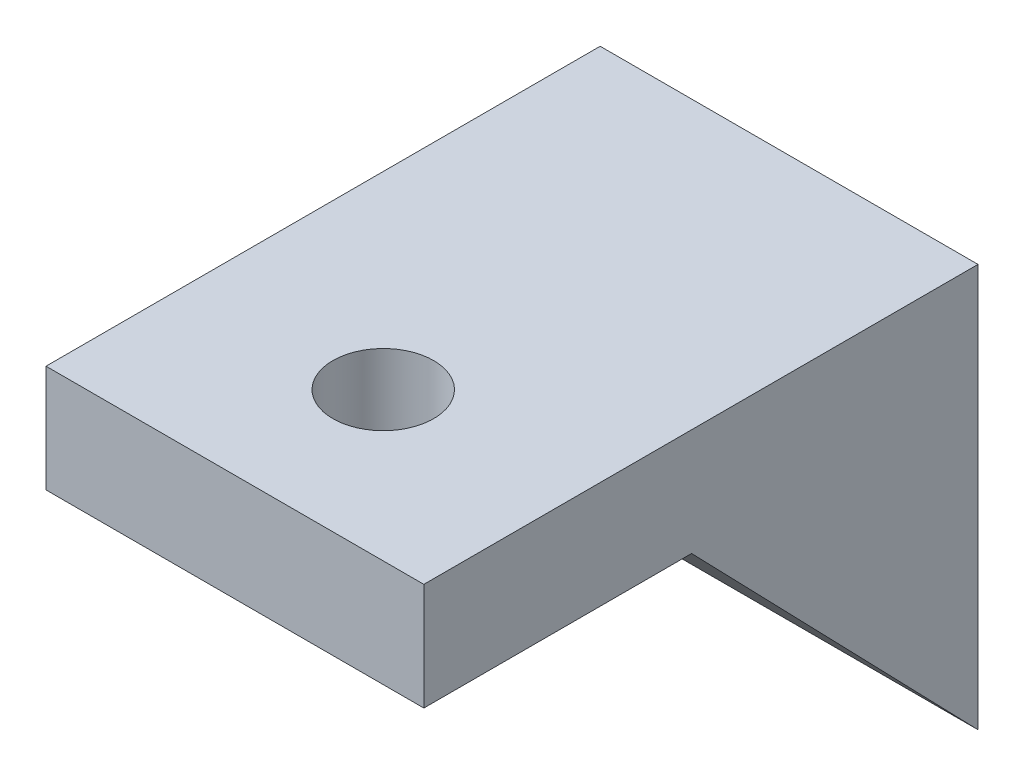
from build123d import *

# Parameters (mm, degrees)
SKETCH1_W               = 15
SKETCH1_H               = 16
BOSS_EXTRUDE1_DEPTH     = 22
CUT_EXTRUDE1_DEPTH      = 22
CUT_EXTRUDE1_DEPTH_BACK = 22
SKETCH6_R               = 2
CUT_EXTRUDE2_DEPTH      = 22
SKETCH7_R               = 2
CUT_EXTRUDE3_DEPTH      = 10


with BuildPart() as part:
    # Sketch1 → Boss-Extrude1 (new body)
    with BuildSketch(Plane.XY):
        Rectangle(SKETCH1_W, SKETCH1_H)
    extrude(amount=BOSS_EXTRUDE1_DEPTH)

    # Sketch4 → Cut-Extrude1 (cut, two sides)
    with BuildSketch(Plane(origin=(0, 0, 0), x_dir=(0, 0, -1), z_dir=(1, 0, 0))) as cut_extrude1_sk:
        Polygon((-22, 3.745733089), (-11.369948947, 3.745733089), (0, -8), (-22, -8), align=None)
    extrude(amount=CUT_EXTRUDE1_DEPTH, mode=Mode.SUBTRACT)
    extrude(cut_extrude1_sk.sketch, amount=-CUT_EXTRUDE1_DEPTH_BACK, mode=Mode.SUBTRACT)

    # Sketch6 → Cut-Extrude2 (cut)
    with BuildSketch(Plane(origin=(0, 8, 0), x_dir=(1, 0, 0), z_dir=(0, 1, 0))):
        with Locations((0, -16.110735895)):
            Circle(SKETCH6_R)
    extrude(amount=-CUT_EXTRUDE2_DEPTH, mode=Mode.SUBTRACT)

    # Sketch7 → Cut-Extrude3 (cut)
    with BuildSketch(Plane(origin=(0, 0, 0), x_dir=(-1, 0, 0), z_dir=(0, 0, -1))):
        Circle(SKETCH7_R)
    extrude(amount=-CUT_EXTRUDE3_DEPTH, mode=Mode.SUBTRACT)


solid = part.part
